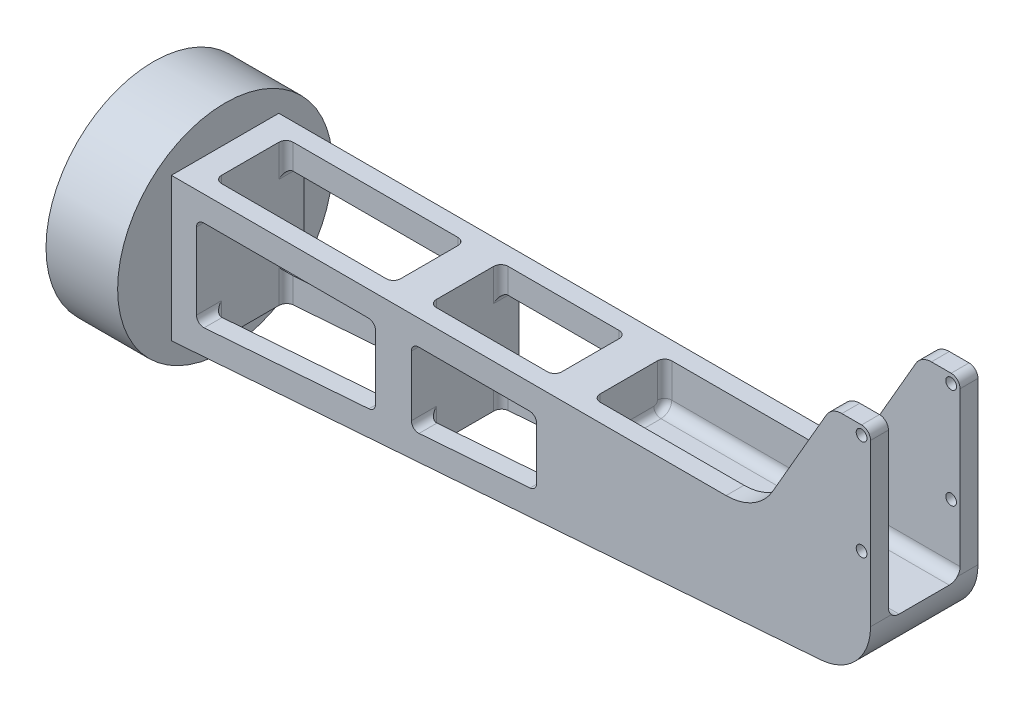
from build123d import *

# Parameters (mm, degrees)
SKETCH2_R               = 1.5
BOSS_EXTRUDE1_DEPTH     = 15
CUT_EXTRUDE1_DEPTH      = 3.5
CUT_EXTRUDE1_DEPTH_BACK = 80
SKETCH4_R               = 30
BOSS_EXTRUDE2_DEPTH     = 20
FILLET1_R               = 2
CUT_EXTRUDE2_DEPTH      = 31
CUT_EXTRUDE2_DEPTH_BACK = 31
CUT_EXTRUDE3_DEPTH      = 31.5
CUT_EXTRUDE3_DEPTH_BACK = 56.5


with BuildPart() as part:
    # Sketch2 → Boss-Extrude1 (new body, symmetric)
    with BuildSketch(Plane.XY):
        with BuildLine():
            Line((2.5, -17.041406268), (2.5, 28))
            ThreePointArc((2.5, 28), (1.767766953, 29.767766953), (0, 30.5))
            Line((0, 30.5), (-5.5, 30.5))
            ThreePointArc((-5.5, 30.5), (-8, 29.830127019), (-9.830127019, 28))
            Line((-9.830127019, 28), (-24.841234018, 2))
            ThreePointArc((-24.841234018, 2), (-30.331615075, -3.490381057), (-37.831615075, -5.5))
            Line((-37.831615075, -5.5), (-192.7, -5.5))
            Line((-192.7, -5.5), (-192.7, -45.5))
            Line((-192.7, -45.5), (-11.386234507, -32))
            ThreePointArc((-11.386234507, -32), (-1.506672879, -27.246638201), (2.5, -17.041406268))
        make_face()
        with Locations((0, 28)):
            Circle(SKETCH2_R, mode=Mode.SUBTRACT)
        Circle(SKETCH2_R, mode=Mode.SUBTRACT)
    extrude(amount=BOSS_EXTRUDE1_DEPTH, both=True)

    # Sketch3 → Cut-Extrude1 (cut, two sides)
    with BuildSketch(Plane(origin=(0, 0, 0), x_dir=(0, 0, -1), z_dir=(1, 0, 0))) as cut_extrude1_sk:
        with BuildLine():
            Line((-7, -18), (7, -18))
            ThreePointArc((7, -18), (9.121320344, -17.121320344), (10, -15))
            Line((10, -15), (10, 30.5))
            Line((10, 30.5), (-10, 30.5))
            Line((-10, 30.5), (-10, -15))
            ThreePointArc((-10, -15), (-9.121320344, -17.121320344), (-7, -18))
        make_face()
    extrude(amount=CUT_EXTRUDE1_DEPTH, mode=Mode.SUBTRACT)
    extrude(cut_extrude1_sk.sketch, amount=-CUT_EXTRUDE1_DEPTH_BACK, mode=Mode.SUBTRACT)

    # Sketch4 → Boss-Extrude2 (add)
    with BuildSketch(Plane(origin=(-192.7, 0, 0), x_dir=(0, 0, -1), z_dir=(1, 0, 0))):
        with Locations((0, -25.5)):
            Circle(SKETCH4_R)
    extrude(amount=-BOSS_EXTRUDE2_DEPTH)

    # Fillet1
    fillet1_edges = [part.edges().sort_by_distance(p)[0] for p in [
        (-80, -18, 0),
        (-80, -17.121320344, 9.121320344),
        (-80, -17.121320344, -9.121320344),
        (-80, -10.25, -10),
        (-80, -10.25, 10),
    ]]
    fillet(fillet1_edges, radius=FILLET1_R)

    # Sketch5 → Cut-Extrude2 (cut, two sides)
    with BuildSketch(Plane.XY) as cut_extrude2_sk:
        with BuildLine():
            Line((-185.7, -14.5), (-185.7, -35.804978393))
            ThreePointArc((-185.7, -35.804978393), (-185.060697591, -37.270755343), (-183.551497934, -37.799457557))
            Line((-183.551497934, -37.799457557), (-137.551497934, -34.374455609))
            ThreePointArc((-137.551497934, -34.374455609), (-136.23422305, -33.740674036), (-135.7, -32.379976445))
            Line((-135.7, -32.379976445), (-135.7, -14.5))
            ThreePointArc((-135.7, -14.5), (-136.285786438, -13.085786438), (-137.7, -12.5))
            Line((-137.7, -12.5), (-183.7, -12.5))
            ThreePointArc((-183.7, -12.5), (-185.114213562, -13.085786438), (-185.7, -14.5))
        make_face()
        with BuildLine():
            Line((-125.7, -14.5), (-125.7, -31.337584548))
            ThreePointArc((-125.7, -31.337584548), (-125.060697591, -32.803361498), (-123.551497934, -33.332063712))
            Line((-123.551497934, -33.332063712), (-92.551497934, -31.023910226))
            ThreePointArc((-92.551497934, -31.023910226), (-91.23422305, -30.390128652), (-90.7, -29.029431061))
            Line((-90.7, -29.029431061), (-90.7, -14.5))
            ThreePointArc((-90.7, -14.5), (-91.285786438, -13.085786438), (-92.7, -12.5))
            Line((-92.7, -12.5), (-123.7, -12.5))
            ThreePointArc((-123.7, -12.5), (-125.114213562, -13.085786438), (-125.7, -14.5))
        make_face()
    extrude(amount=CUT_EXTRUDE2_DEPTH, mode=Mode.SUBTRACT)
    extrude(cut_extrude2_sk.sketch, amount=-CUT_EXTRUDE2_DEPTH_BACK, mode=Mode.SUBTRACT)

    # Sketch6 → Cut-Extrude3 (cut, two sides)
    with BuildSketch(Plane(origin=(0, 0, 0), x_dir=(1, 0, 0), z_dir=(0, 1, 0))) as cut_extrude3_sk:
        with BuildLine():
            Line((-183.7, 10), (-137.7, 10))
            ThreePointArc((-137.7, 10), (-136.285786438, 9.414213562), (-135.7, 8))
            Line((-135.7, 8), (-135.7, -8))
            ThreePointArc((-135.7, -8), (-136.285786438, -9.414213562), (-137.7, -10))
            Line((-137.7, -10), (-183.7, -10))
            ThreePointArc((-183.7, -10), (-185.114213562, -9.414213562), (-185.7, -8))
            Line((-185.7, -8), (-185.7, 8))
            ThreePointArc((-185.7, 8), (-185.114213562, 9.414213562), (-183.7, 10))
        make_face()
        with BuildLine():
            Line((-123.7, 10), (-92.7, 10))
            ThreePointArc((-92.7, 10), (-91.285786438, 9.414213562), (-90.7, 8))
            Line((-90.7, 8), (-90.7, -8))
            ThreePointArc((-90.7, -8), (-91.285786438, -9.414213562), (-92.7, -10))
            Line((-92.7, -10), (-123.7, -10))
            ThreePointArc((-123.7, -10), (-125.114213562, -9.414213562), (-125.7, -8))
            Line((-125.7, -8), (-125.7, 8))
            ThreePointArc((-125.7, 8), (-125.114213562, 9.414213562), (-123.7, 10))
        make_face()
    extrude(amount=CUT_EXTRUDE3_DEPTH, mode=Mode.SUBTRACT)
    extrude(cut_extrude3_sk.sketch, amount=-CUT_EXTRUDE3_DEPTH_BACK, mode=Mode.SUBTRACT)


solid = part.part
